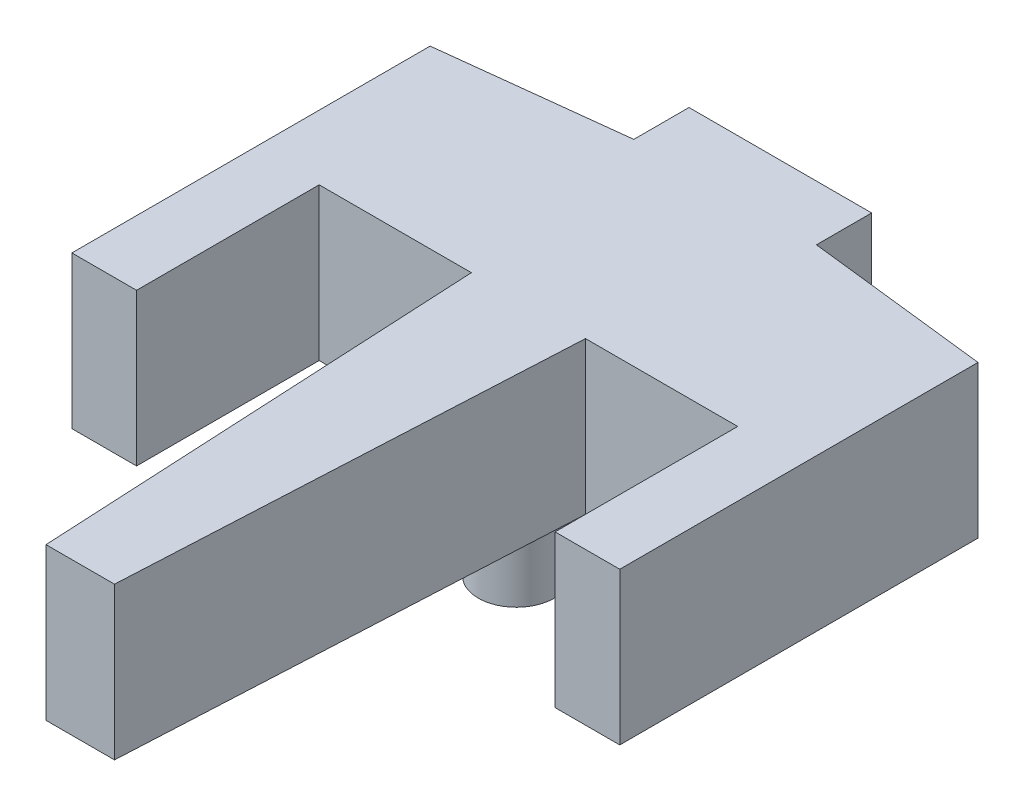
from build123d import *

# Parameters (mm, degrees)
BOSS_EXTRUDE1_DEPTH = 10
SKETCH2_R           = 2.5
BOSS_EXTRUDE2_DEPTH = 5


with BuildPart() as part:
    # Sketch1 → Boss-Extrude1 (new body)
    with BuildSketch(Plane(origin=(0, 0, 0), x_dir=(1, 0, 0), z_dir=(0, 1, 0))):
        Polygon((21.277713785, 48.057856326), (33.277713785, 48.057856326), (33.277713785, 44.431129223), (45.277713785, 43.046501314), (45.277713785, 19.507826857), (41.027713785, 19.507826857), (41.027713785, 31.507826857), (31.027713785, 31.507826857), (29.527713785, 2.057856326), (25.027713785, 2.057856326), (23.527713785, 31.507826857), (13.527713785, 31.507826857), (13.527713785, 19.507826857), (9.277713785, 19.507826857), (9.277713785, 43.046501314), (21.277713785, 44.431129223), align=None)
    extrude(amount=BOSS_EXTRUDE1_DEPTH)

    # Sketch2 → Boss-Extrude2 (add)
    with BuildSketch(Plane(origin=(0, 0, 0), x_dir=(-1, 0, 0), z_dir=(0, -1, 0))):
        with Locations((-27.277713785, 30.711934537)):
            Circle(SKETCH2_R)
    extrude(amount=BOSS_EXTRUDE2_DEPTH)


solid = part.part
